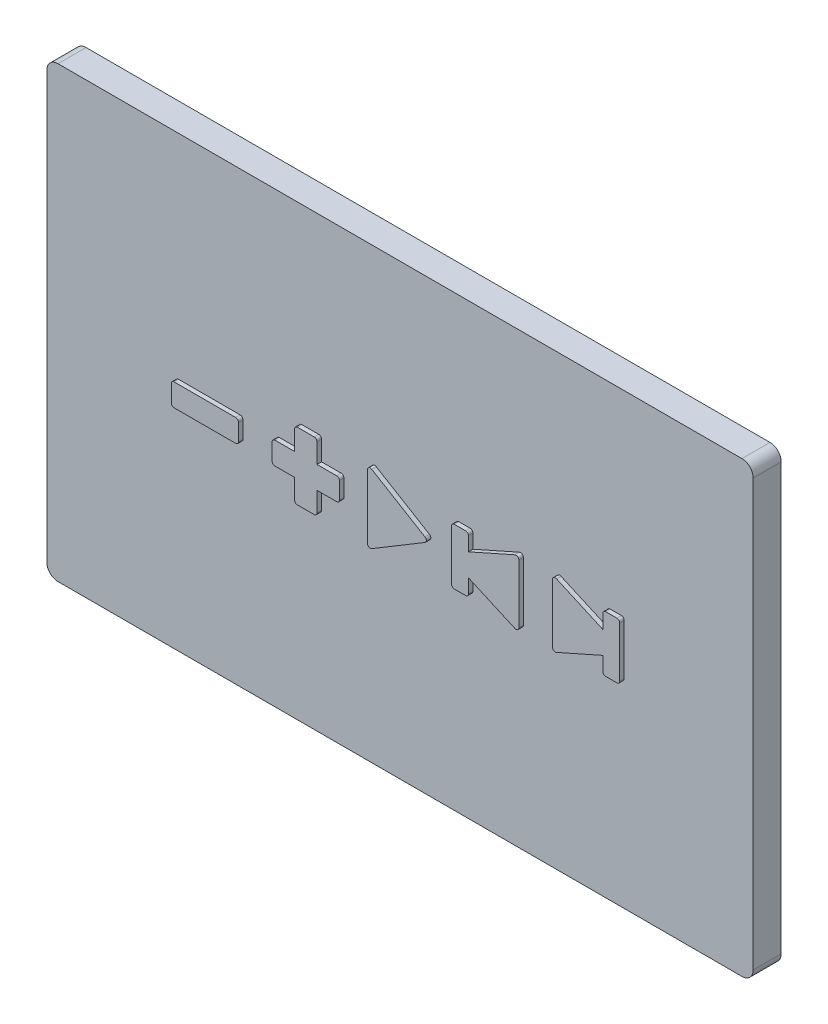
from build123d import *

# Parameters (mm, degrees)
BOSS_EXTRUDE1_DEPTH = 5
BOSS_EXTRUDE2_DEPTH = 0.8
SKETCH22_R          = 0.6
CUT_EXTRUDE1_DEPTH  = 2


with BuildPart() as part:
    # Sketch1 → Boss-Extrude1 (new body)
    with BuildSketch(Plane.XY):
        with BuildLine():
            Line((-61, 40), (61, 40))
            ThreePointArc((61, 40), (62.414213562, 39.414213562), (63, 38))
            Line((63, 38), (63, -38))
            ThreePointArc((63, -38), (62.414213562, -39.414213562), (61, -40))
            Line((61, -40), (-61, -40))
            ThreePointArc((-61, -40), (-62.414213562, -39.414213562), (-63, -38))
            Line((-63, -38), (-63, 38))
            ThreePointArc((-63, 38), (-62.414213562, 39.414213562), (-61, 40))
        make_face()
    extrude(amount=BOSS_EXTRUDE1_DEPTH)

    # Sketch19 → Boss-Extrude2 (add)
    with BuildSketch(Plane.XY.offset(5)):
        with BuildLine():
            Line((-5, 5.7), (-5, -5.7))
            ThreePointArc((-5, -5.7), (-4.746349407, -6.135099953), (-4.242752122, -6.128746463))
            Line((-4.242752122, -6.128746463), (5.257247878, -0.428746463))
            ThreePointArc((5.257247878, -0.428746463), (5.5, 0), (5.257247878, 0.428746463))
            Line((5.257247878, 0.428746463), (-4.242752122, 6.128746463))
            ThreePointArc((-4.242752122, 6.128746463), (-4.746349407, 6.135099953), (-5, 5.7))
        make_face()
        with BuildLine():
            Line((-10, -1.5), (-10, 1.5))
            ThreePointArc((-10, 1.5), (-10.146446609, 1.853553391), (-10.5, 2))
            Line((-10.5, 2), (-14, 2))
            Line((-14, 2), (-14, 5.5))
            ThreePointArc((-14, 5.5), (-14.146446609, 5.853553391), (-14.5, 6))
            Line((-14.5, 6), (-17.5, 6))
            ThreePointArc((-17.5, 6), (-17.853553391, 5.853553391), (-18, 5.5))
            Line((-18, 5.5), (-18, 2))
            Line((-18, 2), (-21.5, 2))
            ThreePointArc((-21.5, 2), (-21.853553391, 1.853553391), (-22, 1.5))
            Line((-22, 1.5), (-22, -1.5))
            ThreePointArc((-22, -1.5), (-21.853553391, -1.853553391), (-21.5, -2))
            Line((-21.5, -2), (-18, -2))
            Line((-18, -2), (-18, -5.5))
            ThreePointArc((-18, -5.5), (-17.853553391, -5.853553391), (-17.5, -6))
            Line((-17.5, -6), (-14.5, -6))
            ThreePointArc((-14.5, -6), (-14.146446609, -5.853553391), (-14, -5.5))
            Line((-14, -5.5), (-14, -2))
            Line((-14, -2), (-10.5, -2))
            ThreePointArc((-10.5, -2), (-10.146446609, -1.853553391), (-10, -1.5))
        make_face()
        with BuildLine():
            Line((-28, 1.5), (-28, -1.5))
            ThreePointArc((-28, -1.5), (-28.146446609, -1.853553391), (-28.5, -2))
            Line((-28.5, -2), (-39.5, -2))
            ThreePointArc((-39.5, -2), (-39.853553391, -1.853553391), (-40, -1.5))
            Line((-40, -1.5), (-40, 1.5))
            ThreePointArc((-40, 1.5), (-39.853553391, 1.853553391), (-39.5, 2))
            Line((-39.5, 2), (-28.5, 2))
            ThreePointArc((-28.5, 2), (-28.146446609, 1.853553391), (-28, 1.5))
        make_face()
        with BuildLine():
            Line((10, 4.5), (10, -4.5))
            ThreePointArc((10, -4.5), (10.146446609, -4.853553391), (10.5, -5))
            Line((10.5, -5), (12.5, -5))
            ThreePointArc((12.5, -5), (12.853553391, -4.853553391), (13, -4.5))
            Line((13, -4.5), (13, -2))
            Line((13, -2), (21.296930767, -5.687524785))
            ThreePointArc((21.296930767, -5.687524785), (21.77245677, -5.64986513), (22, -5.230619011))
            Line((22, -5.230619011), (22, 5.230619011))
            ThreePointArc((22, 5.230619011), (21.77245677, 5.64986513), (21.296930767, 5.687524785))
            Line((21.296930767, 5.687524785), (13, 2))
            Line((13, 2), (13, 4.5))
            ThreePointArc((13, 4.5), (12.853553391, 4.853553391), (12.5, 5))
            Line((12.5, 5), (10.5, 5))
            ThreePointArc((10.5, 5), (10.146446609, 4.853553391), (10, 4.5))
        make_face()
        with BuildLine():
            Line((28, 5.230619011), (28, -5.230619011))
            ThreePointArc((28, -5.230619011), (28.22754323, -5.64986513), (28.703069233, -5.687524785))
            Line((28.703069233, -5.687524785), (37, -2))
            Line((37, -2), (37, -4.5))
            ThreePointArc((37, -4.5), (37.146446609, -4.853553391), (37.5, -5))
            Line((37.5, -5), (39.5, -5))
            ThreePointArc((39.5, -5), (39.853553391, -4.853553391), (40, -4.5))
            Line((40, -4.5), (40, 4.5))
            ThreePointArc((40, 4.5), (39.853553391, 4.853553391), (39.5, 5))
            Line((39.5, 5), (37.5, 5))
            ThreePointArc((37.5, 5), (37.146446609, 4.853553391), (37, 4.5))
            Line((37, 4.5), (37, 2))
            Line((37, 2), (28.703069233, 5.687524785))
            ThreePointArc((28.703069233, 5.687524785), (28.22754323, 5.64986513), (28, 5.230619011))
        make_face()
    extrude(amount=BOSS_EXTRUDE2_DEPTH)

    # Sketch22 → Cut-Extrude1 (cut)
    with BuildSketch(Plane.XY):
        with Locations((-34, 0)):
            Circle(SKETCH22_R)
        with Locations((-16, 0)):
            Circle(SKETCH22_R)
        with Locations((-1, 0)):
            Circle(SKETCH22_R)
        with Locations((17, 0)):
            Circle(SKETCH22_R)
        with Locations((33, 0)):
            Circle(SKETCH22_R)
    extrude(amount=CUT_EXTRUDE1_DEPTH, mode=Mode.SUBTRACT)


solid = part.part
